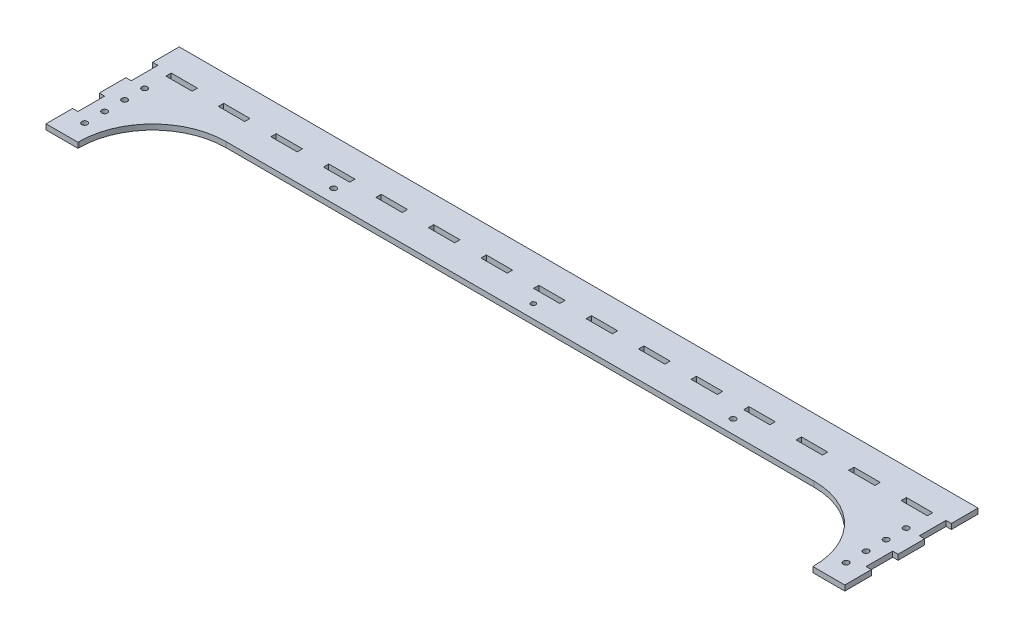
from build123d import *

# Parameters (mm, degrees)
SKETCH1_R           = 2.125
SKETCH1_R_2         = 1.787095899
SKETCH1_W           = 19.725
SKETCH1_H           = 4
BOSS_EXTRUDE1_DEPTH = 4


with BuildPart() as part:
    # Sketch1 → Boss-Extrude1 (new body)
    with BuildSketch(Plane(origin=(0, 0, 0), x_dir=(1, 0, 0), z_dir=(0, 1, 0))):
        with BuildLine():
            Line((299.8, 24), (299.8, 4))
            Line((299.8, 4), (295.8, 4))
            Line((295.8, 4), (295.8, -16))
            Line((295.8, -16), (299.8, -16))
            Line((299.8, -16), (299.8, -36))
            Line((299.8, -36), (295.8, -36))
            Line((295.8, -36), (295.8, -56))
            Line((295.8, -56), (299.8, -56))
            Line((299.8, -56), (299.8, -76))
            Line((299.8, -76), (275.8, -76))
            Line((275.8, -76), (275.8, -75))
            ThreePointArc((275.8, -75), (259.690872965, -36.109127035), (220.8, -20))
            Line((220.8, -20), (-220.8, -20))
            ThreePointArc((-220.8, -20), (-259.690872965, -36.109127035), (-275.8, -75))
            Line((-275.8, -75), (-275.8, -76))
            Line((-275.8, -76), (-299.8, -76))
            Line((-299.8, -76), (-299.8, -56))
            Line((-299.8, -56), (-295.8, -56))
            Line((-295.8, -56), (-295.8, -36))
            Line((-295.8, -36), (-299.8, -36))
            Line((-299.8, -36), (-299.8, -16))
            Line((-299.8, -16), (-295.8, -16))
            Line((-295.8, -16), (-295.8, 4))
            Line((-295.8, 4), (-299.8, 4))
            Line((-299.8, 4), (-299.8, 24))
            Line((-299.8, 24), (299.8, 24))
        make_face()
        with Locations((285.8, -61)):
            Circle(SKETCH1_R, mode=Mode.SUBTRACT)
        with Locations((285.8, -46)):
            Circle(SKETCH1_R, mode=Mode.SUBTRACT)
        with Locations((-285.8, -46)):
            Circle(SKETCH1_R, mode=Mode.SUBTRACT)
        with Locations((-285.8, -61)):
            Circle(SKETCH1_R, mode=Mode.SUBTRACT)
        with Locations((285.8, -16)):
            Circle(SKETCH1_R, mode=Mode.SUBTRACT)
        with Locations((285.8, -31)):
            Circle(SKETCH1_R, mode=Mode.SUBTRACT)
        with Locations((-285.8, -31)):
            Circle(SKETCH1_R, mode=Mode.SUBTRACT)
        with Locations((-285.8, -16)):
            Circle(SKETCH1_R, mode=Mode.SUBTRACT)
        with Locations((-149.9, -10)):
            Circle(SKETCH1_R, mode=Mode.SUBTRACT)
        with Locations((149.9, -10)):
            Circle(SKETCH1_R, mode=Mode.SUBTRACT)
        with Locations((0, -10)):
            Circle(SKETCH1_R_2, mode=Mode.SUBTRACT)
        with Locations((0, 2)):
            Rectangle(SKETCH1_W, SKETCH1_H, mode=Mode.SUBTRACT)
        with Locations((39.45, 2)):
            Rectangle(SKETCH1_W, SKETCH1_H, mode=Mode.SUBTRACT)
        with Locations((78.87, 2)):
            Rectangle(SKETCH1_W, SKETCH1_H, mode=Mode.SUBTRACT)
        with Locations((118.29, 2)):
            Rectangle(SKETCH1_W, SKETCH1_H, mode=Mode.SUBTRACT)
        with Locations((157.71, 2)):
            Rectangle(SKETCH1_W, SKETCH1_H, mode=Mode.SUBTRACT)
        with Locations((197.13, 2)):
            Rectangle(SKETCH1_W, SKETCH1_H, mode=Mode.SUBTRACT)
        with Locations((236.55, 2)):
            Rectangle(SKETCH1_W, SKETCH1_H, mode=Mode.SUBTRACT)
        with Locations((275.97, 2)):
            Rectangle(SKETCH1_W, SKETCH1_H, mode=Mode.SUBTRACT)
        with Locations((-275.97, 2)):
            Rectangle(SKETCH1_W, SKETCH1_H, mode=Mode.SUBTRACT)
        with Locations((-236.55, 2)):
            Rectangle(SKETCH1_W, SKETCH1_H, mode=Mode.SUBTRACT)
        with Locations((-197.13, 2)):
            Rectangle(SKETCH1_W, SKETCH1_H, mode=Mode.SUBTRACT)
        with Locations((-157.71, 2)):
            Rectangle(SKETCH1_W, SKETCH1_H, mode=Mode.SUBTRACT)
        with Locations((-118.29, 2)):
            Rectangle(SKETCH1_W, SKETCH1_H, mode=Mode.SUBTRACT)
        with Locations((-78.87, 2)):
            Rectangle(SKETCH1_W, SKETCH1_H, mode=Mode.SUBTRACT)
        with Locations((-39.45, 2)):
            Rectangle(SKETCH1_W, SKETCH1_H, mode=Mode.SUBTRACT)
    extrude(amount=BOSS_EXTRUDE1_DEPTH)


solid = part.part
